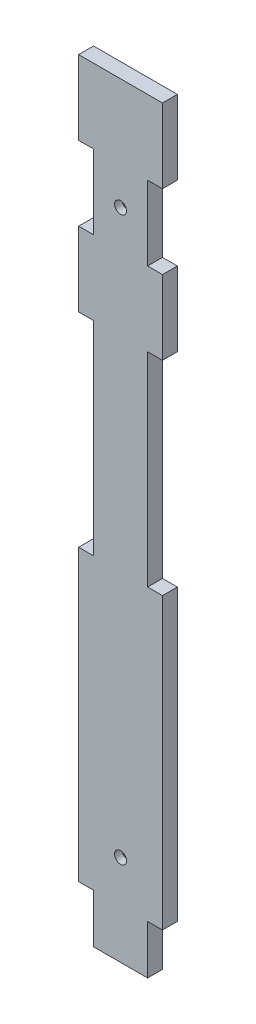
from build123d import *

# Parameters (mm, degrees)
SKETCH1_R           = 4
BOSS_EXTRUDE1_DEPTH = 10
CHAMFER1_SIZE       = 5


with BuildPart() as part:
    # Sketch1 → Boss-Extrude1 (new body)
    with BuildSketch(Plane.XY):
        Polygon((0, 150), (56.4, 150), (56.4, 100), (46.4, 100), (46.4, 50), (56.4, 50), (56.4, 0), (46.4, 0), (46.4, -137.127452116), (56.4, -137.127452116), (56.4, -332.021266673), (46.4, -332.021266673), (46.4, -365), (10, -365), (10, -332.021266673), (0, -332.021266673), (0, -137.127452116), (10, -137.127452116), (10, 0), (0, 0), (0, 50), (10, 50), (10, 100), (0, 100), align=None)
        with Locations((28.2, 75)):
            Circle(SKETCH1_R, mode=Mode.SUBTRACT)
        with Locations((28.2, -303.821266673)):
            Circle(SKETCH1_R, mode=Mode.SUBTRACT)
    extrude(amount=BOSS_EXTRUDE1_DEPTH)

    # Chamfer1
    chamfer1_edges = [part.edges().sort_by_distance(p)[0] for p in [
        (24.2, 75, 0),
        (24.2, -303.821266673, 0),
    ]]
    chamfer(chamfer1_edges, length=CHAMFER1_SIZE)


solid = part.part
